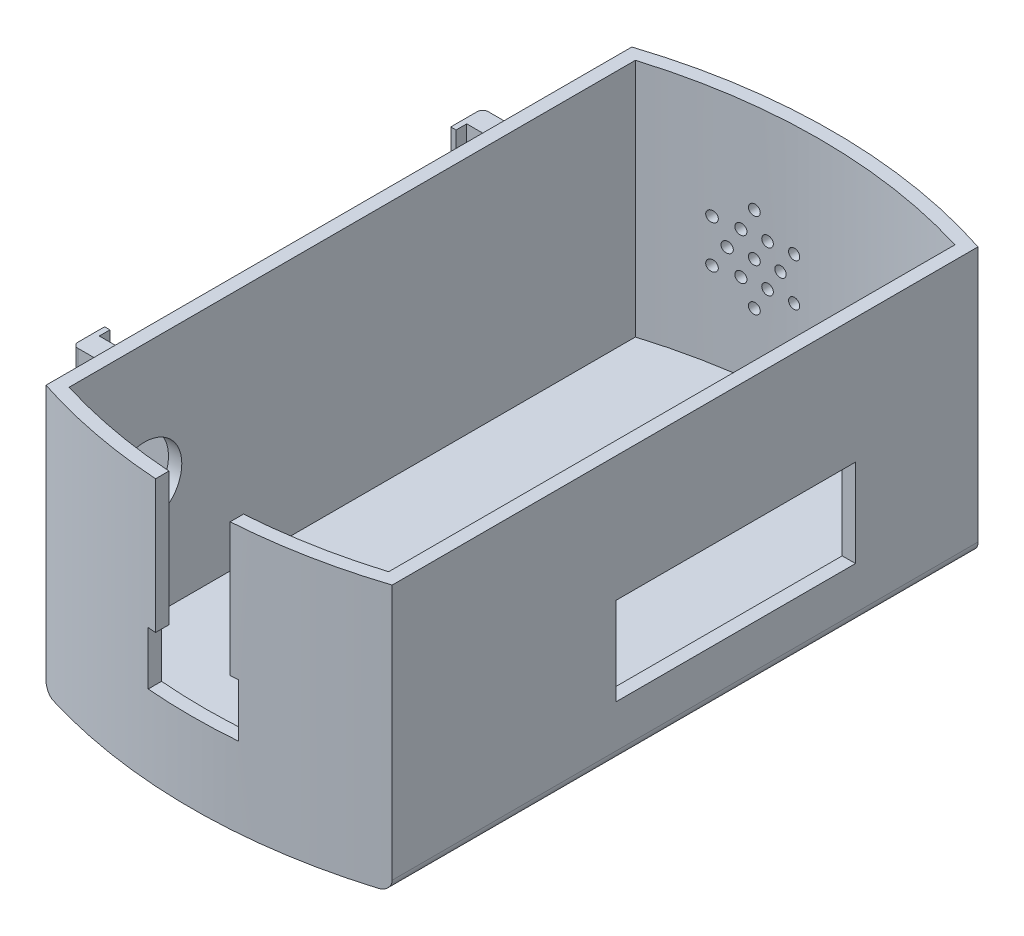
from build123d import *

# Parameters (mm, degrees)
BOSS_EXTRUDE1_DEPTH      = 50
SHELL2_T                 = -2.5
SHELL2_THICKNESS_2_DEPTH = 2.5
SKETCH11_R               = 7
CUT_EXTRUDE7_DEPTH       = 20
FILLET1_R                = 2
SKETCH16_W               = 55
SKETCH16_H               = 3
SKETCH16_W_2             = 4
SKETCH16_H_2             = 25
BOSS_EXTRUDE7_DEPTH      = 22
BOSS_EXTRUDE8_START      = -4
SKETCH17_W               = 1
SKETCH17_H               = 25
BOSS_EXTRUDE8_DEPTH      = 6
SKETCH18_W               = 1
SKETCH18_H               = 25
BOSS_EXTRUDE9_DEPTH      = 6
FILLET3_R                = 1
SKETCH3_W                = 45
SKETCH3_H                = 16.5
CUT_EXTRUDE8_DEPTH       = 10
SKETCH20_R               = 2.55
CUT_EXTRUDE9_DEPTH       = 100
SKETCH21_R               = 1
CUT_EXTRUDE10_DEPTH      = 100
CUT_EXTRUDE11_DEPTH      = 100


with BuildPart() as part:
    # Sketch1 → Boss-Extrude1 (new body)
    with BuildSketch(Plane(origin=(0, 0, 0), x_dir=(1, 0, 0), z_dir=(0, 1, 0))):
        with BuildLine():
            Line((-32.5, 55), (-32.5, -55))
            ThreePointArc((-32.5, -55), (0, -60.156372261), (32.5, -55))
            Line((32.5, -55), (32.5, 55))
            ThreePointArc((32.5, 55), (0, 60.156372261), (-32.5, 55))
        make_face()
    extrude(amount=BOSS_EXTRUDE1_DEPTH)

    # Shell2
    shell2_openings = [part.faces().sort_by_distance(p)[0] for p in [
        (0, 50, 0),
    ]]
    offset(amount=SHELL2_T, openings=shell2_openings, kind=Kind.INTERSECTION)

    # Shell2 thickness 2 face (on inner face of the shell) → Shell2 thickness 2 (add)
    with BuildSketch(Plane(origin=(0, 2.5, 0), x_dir=(0, 0, -1), z_dir=(0, -1, 0))):
        with BuildLine():
            Line((53.167851181, -30), (-53.167851181, -30))
            ThreePointArc((-53.167851181, -30), (-57.656372261, 0), (-53.167851181, 30))
            Line((-53.167851181, 30), (53.167851181, 30))
            ThreePointArc((53.167851181, 30), (57.656372261, 0), (53.167851181, -30))
        make_face()
    extrude(amount=-SHELL2_THICKNESS_2_DEPTH)

    # Sketch11 → Cut-Extrude7 (cut)
    with BuildSketch(Plane.ZY.offset(32.5)):
        with Locations((39, 27)):
            Circle(SKETCH11_R)
    extrude(amount=-CUT_EXTRUDE7_DEPTH, mode=Mode.SUBTRACT)

    # Fillet1
    fillet1_edges = [part.edges().sort_by_distance(p)[0] for p in [
        (-32.5, 0, 0),
        (32.5, 0, 0),
    ]]
    fillet(fillet1_edges, radius=FILLET1_R)

    # Sketch16 → Boss-Extrude7 (add)
    with BuildSketch(Plane.ZY.offset(32.5)):
        with Locations((-13.5, 3.5)):
            Rectangle(SKETCH16_W, SKETCH16_H)
        with Locations((25, 18.5)):
            Rectangle(SKETCH16_W_2, SKETCH16_H_2)
        with Locations((-48, 18.5)):
            Rectangle(SKETCH16_W_2, SKETCH16_H_2)
    extrude(amount=BOSS_EXTRUDE7_DEPTH)

    # Sketch17 → Boss-Extrude8 (add)
    with BuildSketch(Plane.XY.offset(-46).offset(BOSS_EXTRUDE8_START)):
        with Locations((-55, 18.5)):
            Rectangle(SKETCH17_W, SKETCH17_H)
    extrude(amount=BOSS_EXTRUDE8_DEPTH)

    # Sketch18 → Boss-Extrude9 (add)
    with BuildSketch(Plane.XY.offset(27)):
        with Locations((-55, 18.5)):
            Rectangle(SKETCH18_W, SKETCH18_H)
    extrude(amount=-BOSS_EXTRUDE9_DEPTH)

    # Fillet3
    fillet3_edges = [part.edges().sort_by_distance(p)[0] for p in [
        (-55.5, 18.5, -50),
        (-55.5, 18.5, 27),
    ]]
    fillet(fillet3_edges, radius=FILLET3_R)

    # Sketch3 → Cut-Extrude8 (cut)
    with BuildSketch(Plane(origin=(32.5, 0, 0), x_dir=(0, 0, -1), z_dir=(1, 0, 0))):
        with Locations((9.5, 18.25)):
            Rectangle(SKETCH3_W, SKETCH3_H)
    extrude(amount=-CUT_EXTRUDE8_DEPTH, mode=Mode.SUBTRACT)

    # Sketch20 → Cut-Extrude9 (cut)
    with BuildSketch(Plane.XY):
        with Locations((20.5, 25)):
            Circle(SKETCH20_R)
        with Locations((12.5, 25)):
            Circle(SKETCH20_R)
    extrude(amount=-CUT_EXTRUDE9_DEPTH, mode=Mode.SUBTRACT)

    # Sketch21 → Cut-Extrude10 (cut)
    with BuildSketch(Plane.XY):
        with Locations((-11.5, 25)):
            Circle(SKETCH21_R)
        with Locations((-7, 25)):
            Circle(SKETCH21_R)
        with Locations((-9.25, 21.102885683)):
            Circle(SKETCH21_R)
        with Locations((-13.75, 21.102885683)):
            Circle(SKETCH21_R)
        with Locations((-16, 25)):
            Circle(SKETCH21_R)
        with Locations((-13.75, 28.897114317)):
            Circle(SKETCH21_R)
        with Locations((-9.25, 28.897114317)):
            Circle(SKETCH21_R)
        with Locations((-11.5, 33)):
            Circle(SKETCH21_R)
        with Locations((-4.57179677, 29)):
            Circle(SKETCH21_R)
        with Locations((-4.57179677, 21)):
            Circle(SKETCH21_R)
        with Locations((-11.5, 17)):
            Circle(SKETCH21_R)
        with Locations((-18.42820323, 21)):
            Circle(SKETCH21_R)
        with Locations((-18.42820323, 29)):
            Circle(SKETCH21_R)
    extrude(amount=-CUT_EXTRUDE10_DEPTH, mode=Mode.SUBTRACT)

    # Sketch22 → Cut-Extrude11 (cut)
    with BuildSketch(Plane.XY):
        Polygon((-7, 25), (-7, 50), (7, 50), (7, 25), (8.5, 25), (8.5, 15), (-8.5, 15), (-8.5, 25), align=None)
    extrude(amount=CUT_EXTRUDE11_DEPTH, mode=Mode.SUBTRACT)


solid = part.part
